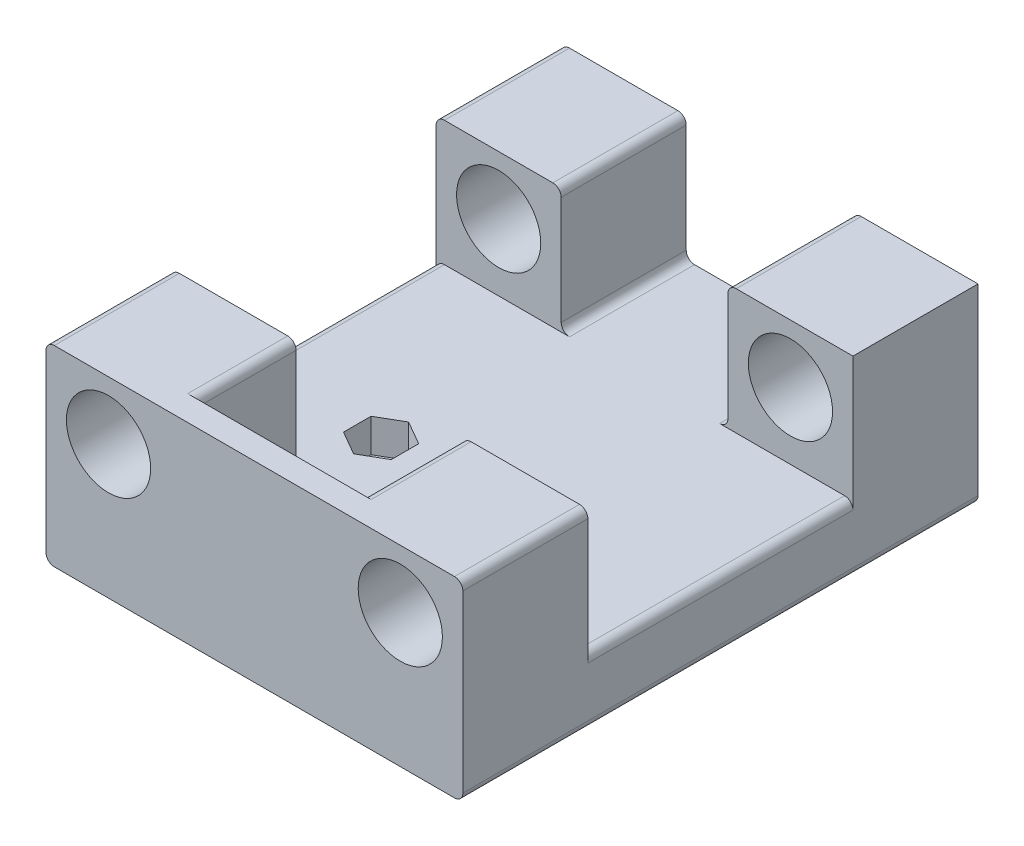
from build123d import *

# Parameters (mm, degrees)
SKETCH1_W               = 50
SKETCH1_H               = 61.8
BOSS_EXTRUDE1_DEPTH     = 5
SKETCH2_W               = 15
SKETCH2_H               = 15
BOSS_EXTRUDE2_DEPTH     = 15
SKETCH3_R               = 5.05
CUT_EXTRUDE1_DEPTH      = 1
CUT_EXTRUDE1_DEPTH_BACK = 62.8
SKETCH4_W               = 20
SKETCH4_H               = 3
BOSS_EXTRUDE3_DEPTH     = 15
SKETCH6_W               = 50
SKETCH6_H               = 61.8
BOSS_EXTRUDE5_DEPTH     = 3
FILLET1_R               = 1
CUT_EXTRUDE2_DEPTH      = 4
M3_CLEARANCE_HOLE1_D    = 3.4


with BuildPart() as part:
    # Sketch1 → Boss-Extrude1 (new body)
    with BuildSketch(Plane(origin=(0, 0, 0), x_dir=(1, 0, 0), z_dir=(0, 1, 0))):
        Rectangle(SKETCH1_W, SKETCH1_H)
    extrude(amount=BOSS_EXTRUDE1_DEPTH)

    # Sketch2 → Boss-Extrude2 (add)
    with BuildSketch(Plane(origin=(0, 5, 0), x_dir=(1, 0, 0), z_dir=(0, 1, 0))):
        with Locations((-17.5, 23.4)):
            Rectangle(SKETCH2_W, SKETCH2_H)
        with Locations((17.5, 23.4)):
            Rectangle(SKETCH2_W, SKETCH2_H)
        with Locations((-17.5, -23.4)):
            Rectangle(SKETCH2_W, SKETCH2_H)
        with Locations((17.5, -23.4)):
            Rectangle(SKETCH2_W, SKETCH2_H)
    extrude(amount=BOSS_EXTRUDE2_DEPTH)

    # Sketch3 → Cut-Extrude1 (cut, two sides)
    with BuildSketch(Plane.XY.offset(30.9)) as cut_extrude1_sk:
        with Locations((-17.5, 13)):
            Circle(SKETCH3_R)
        with Locations((17.5, 13)):
            Circle(SKETCH3_R)
    extrude(amount=CUT_EXTRUDE1_DEPTH, mode=Mode.SUBTRACT)
    extrude(cut_extrude1_sk.sketch, amount=-CUT_EXTRUDE1_DEPTH_BACK, mode=Mode.SUBTRACT)

    # Sketch4 → Boss-Extrude3 (add)
    with BuildSketch(Plane(origin=(0, 5, 0), x_dir=(1, 0, 0), z_dir=(0, 1, 0))):
        with Locations((0, -29.4)):
            Rectangle(SKETCH4_W, SKETCH4_H)
    extrude(amount=BOSS_EXTRUDE3_DEPTH)

    # Sketch6 → Boss-Extrude5 (add)
    with BuildSketch(Plane.XZ):
        Rectangle(SKETCH6_W, SKETCH6_H)
    extrude(amount=BOSS_EXTRUDE5_DEPTH)

    # Fillet1
    fillet1_edges = [part.edges().sort_by_distance(p)[0] for p in [
        (-25, 5, 0),
        (-10, 5, -23.4),
        (-25, 20, -23.4),
        (-10, 20, -23.4),
        (10, 5, -23.4),
        (10, 20, -23.4),
        (-25, 20, 23.4),
        (25, 5, 0),
        (10, 5, 21.9),
        (25, 20, 23.4),
        (10, 20, 21.9),
        (-10, 20, 21.9),
        (-10, 5, 21.9),
        (-25, -3, 0),
        (25, -3, 0),
    ]]
    fillet(fillet1_edges, radius=FILLET1_R)

    # Sketch7 → Cut-Extrude2 (cut)
    with BuildSketch(Plane(origin=(0, 5, 0), x_dir=(1, 0, 0), z_dir=(0, 1, 0))):
        Polygon((-12.657883832, -4.25), (-12.657883832, -7.55), (-9.8, -9.2), (-6.942116168, -7.55), (-6.942116168, -4.25), (-9.8, -2.6), align=None)
        Polygon((12.657883832, -7.55), (12.657883832, -4.25), (9.8, -2.6), (6.942116168, -4.25), (6.942116168, -7.55), (9.8, -9.2), align=None)
    extrude(amount=-CUT_EXTRUDE2_DEPTH, mode=Mode.SUBTRACT)

    # M3 Clearance Hole1 (through all)
    with Locations(Plane(origin=(0, 5, 0), x_dir=(1, 0, 0), z_dir=(0, 1, 0))):
        with Locations((-9.8, -5.9), (9.8, -5.9)):
            Hole(M3_CLEARANCE_HOLE1_D / 2)


solid = part.part
